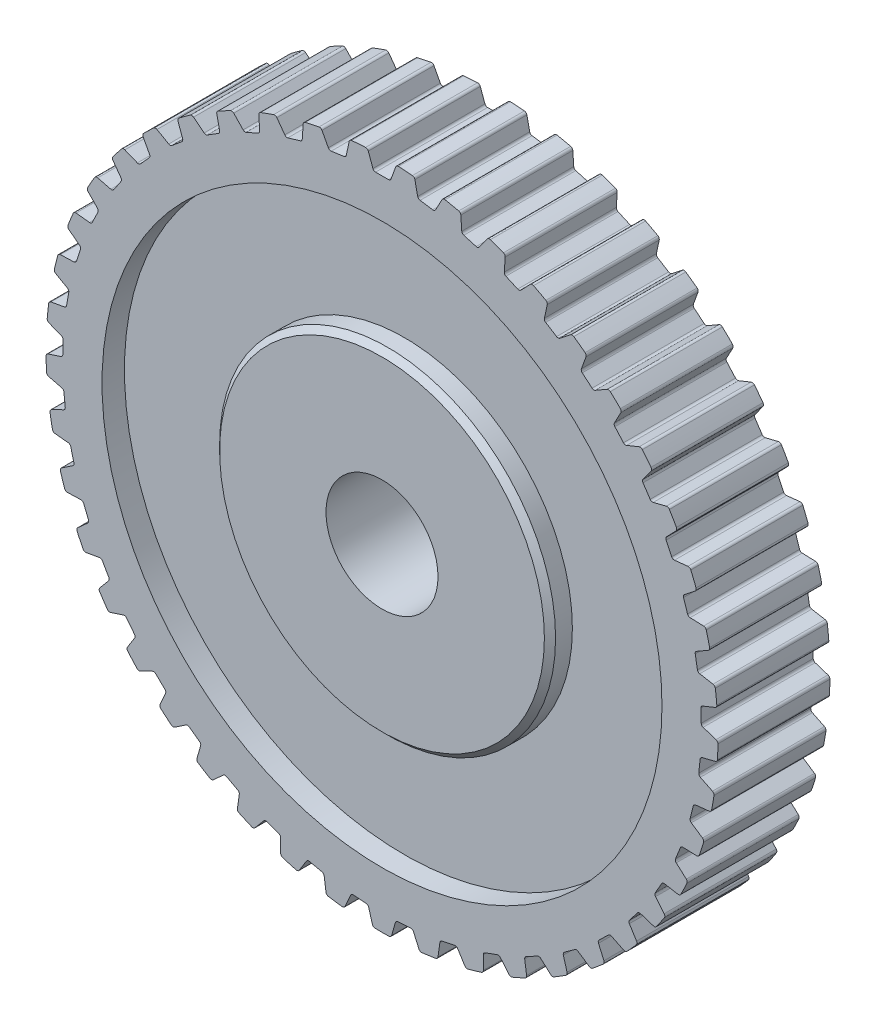
from build123d import *

# Parameters (mm, degrees)
SKETCH2_R               = 30
BOSS_EXTRUDE1_DEPTH     = 10
CUT_EXTRUDE1_START      = -11
CUT_EXTRUDE1_DEPTH      = 12
CIRPATTERN1_COUNT       = 45
SKETCH4_R               = 25
SKETCH4_R_2             = 15
CUT_EXTRUDE_THIN1_DEPTH = 2
CHAMFER1_SIZE           = 0.5
CHAMFER2_SIZE           = 0.5
FILLET1_R               = 0.25
BOSS_EXTRUDE2_DEPTH     = 10


with BuildPart() as part:
    # Sketch2 → Boss-Extrude1 (new body)
    with BuildSketch(Plane.XY):
        Circle(SKETCH2_R)
        with BuildLine():
            Line((2, 4.582575695), (2, 7))
            Line((2, 7), (-2, 7))
            Line((-2, 7), (-2, 4.582575695))
            ThreePointArc((-2, 4.582575695), (0, -5), (2, 4.582575695))
        make_face(mode=Mode.SUBTRACT)
    extrude(amount=BOSS_EXTRUDE1_DEPTH)

    # Sketch3 → Cut-Extrude1 (cut)
    with BuildSketch(Plane.XY.offset(10).offset(CUT_EXTRUDE1_START)):
        Polygon((-50.976281067, 166.495573095), (-1.285919783, 29.972427501), (-0.75, 28.5), (0.75, 28.5), (1.285919783, 29.972427501), (50.976281067, 166.495573095), (50.976281067, 457.065367035), (-50.976281067, 457.065367035), align=None)
    cut_extrude1 = extrude(amount=CUT_EXTRUDE1_DEPTH, mode=Mode.SUBTRACT)

    # CirPattern1: Cut-Extrude1 ×45 about axis
    cirpattern1_axis = Axis((0, 0, 0), (0, 0, 1))
    for i in range(1, CIRPATTERN1_COUNT):
        add(cut_extrude1.rotate(cirpattern1_axis, i * 360 / CIRPATTERN1_COUNT), mode=Mode.SUBTRACT)

    # Sketch4 → Cut-Extrude-Thin1 (cut)
    with BuildSketch(Plane.XY.offset(10)):
        Circle(SKETCH4_R)
        Circle(SKETCH4_R_2, mode=Mode.SUBTRACT)
    cut_extrude_thin1 = extrude(amount=-CUT_EXTRUDE_THIN1_DEPTH, mode=Mode.SUBTRACT)

    # Chamfer1
    chamfer1_edges = [part.edges().sort_by_distance(p)[0] for p in [
        (-15, 0, 10),
    ]]
    chamfer(chamfer1_edges, length=CHAMFER1_SIZE)

    # Mirror1: Cut-Extrude-Thin1 across plane
    add(cut_extrude_thin1.mirror(Plane.XY.offset(5)), mode=Mode.SUBTRACT)

    # Chamfer2
    chamfer2_edges = [part.edges().sort_by_distance(p)[0] for p in [
        (-15, 0, 0),
    ]]
    chamfer(chamfer2_edges, length=CHAMFER2_SIZE)

    # Fillet1
    fillet1_edges = [part.edges().sort_by_distance(p)[0] for p in [
        (5.444760978, 29.501772453, 5),
        (2.897950379, 29.859703341, 5),
        (-2.897950379, 29.859703341, 5),
        (-5.444760978, 29.501772453, 5),
        (-7.025415233, 29.16579402, 5),
        (-9.497626095, 28.456898963, 5),
        (-11.01613837, 27.904205694, 5),
        (-13.365630723, 26.858144303, 5),
        (-14.792444905, 26.099493745, 5),
        (-16.973488552, 24.736626415, 5),
        (-18.280833326, 23.786784837, 5),
        (-20.250976734, 22.133638231, 5),
        (-21.413406121, 21.01109322, 5),
        (-23.134302688, 19.099843956, 5),
        (-24.129191322, 17.826444573, 5),
        (-25.567345756, 15.694292943, 5),
        (-26.375329261, 14.29482446, 5),
        (-27.502749521, 11.983270371, 5),
        (-28.108101418, 10.484971849, 5),
        (-28.90284355, 8.039007072, 5),
        (-29.293781353, 6.471041187, 5),
        (-29.740376607, 3.938273644, 5),
        (-29.909291155, 2.33115907, 5),
        (-29.999047061, -0.2391138, 5),
        (9.497626095, 28.456898963, 5),
        (7.025415233, 29.16579402, 5),
        (13.365630723, 26.858144303, 5),
        (11.01613837, 27.904205694, 5),
        (16.973488552, 24.736626415, 5),
        (14.792444905, 26.099493745, 5),
        (20.250976734, 22.133638231, 5),
        (18.280833326, 23.786784837, 5),
        (23.134302688, 19.099843956, 5),
        (21.413406121, 21.01109322, 5),
        (25.567345756, 15.694292943, 5),
        (24.129191322, 17.826444573, 5),
        (27.502749521, 11.983270371, 5),
        (26.375329261, 14.29482446, 5),
        (28.90284355, 8.039007072, 5),
        (28.108101418, 10.484971849, 5),
        (29.740376607, 3.938273644, 5),
        (29.293781353, 6.471041187, 5),
        (29.999047061, -0.2391138, 5),
        (29.909291155, 2.33115907, 5),
        (29.673820188, -4.411847167, 5),
        (29.942650626, -1.854096408, 5),
        (28.771026159, -8.498708946, 5),
        (29.393210462, -6.003264007, 5),
        (27.308236832, -12.420153023, 5),
        (28.27166489, -10.035584902, 5),
        (25.313923738, -16.099852949, 5),
        (26.59984352, -13.872574552, 5),
        (22.826903912, -19.466187551, 5),
        (24.410286453, -17.439550318, 5),
        (19.895584367, -22.453634955, 5),
        (21.745610926, -20.667085074, 5),
        (16.577019903, -25.004047895, 5),
        (18.657681818, -23.492358527, 5),
        (12.935802603, -27.067785484, 5),
        (15.206602156, -25.860379944, 5),
        (9.042804619, -28.604679418, 5),
        (11.45954328, -27.725058482, 5),
        (4.97379873, -29.584815805, 5),
        (7.48943743, -29.050100292, 5),
        (0.807983505, -29.989117404, 5),
        (3.373558199, -29.809714945, 5),
        (-3.373558199, -29.809714945, 5),
        (-0.807983505, -29.989117404, 5),
        (-7.48943743, -29.050100292, 5),
        (-4.97379873, -29.584815805, 5),
        (-11.45954328, -27.725058482, 5),
        (-9.042804619, -28.604679418, 5),
        (-15.206602156, -25.860379944, 5),
        (-12.935802603, -27.067785484, 5),
        (-18.657681818, -23.492358527, 5),
        (-16.577019903, -25.004047895, 5),
        (-21.745610926, -20.667085074, 5),
        (-19.895584367, -22.453634955, 5),
        (-24.410286453, -17.439550318, 5),
        (-22.826903912, -19.466187551, 5),
        (-26.59984352, -13.872574552, 5),
        (-25.313923738, -16.099852949, 5),
        (-28.27166489, -10.035584902, 5),
        (-27.308236832, -12.420153023, 5),
        (-29.393210462, -6.003264007, 5),
        (-28.771026159, -8.498708946, 5),
        (-29.942650626, -1.854096408, 5),
        (-29.673820188, -4.411847167, 5),
        (0.75, 28.5, 5),
        (-0.75, 28.5, 5),
        (-1.285919783, 29.972427501, 5),
        (1.285919783, 29.972427501, 5),
        (-28.422270365, -2.233169782, 5),
        (-28.265477671, -3.724952625, 5),
        (-27.834869621, -6.16705223, 5),
        (-27.471986777, -7.622495819, 5),
        (-26.7056948, -9.980900021, 5),
        (-26.14378491, -11.371675803, 5),
        (-25.056724008, -13.600480947, 5),
        (-24.306724008, -14.899519053, 5),
        (-22.920052584, -16.955343982, 5),
        (-21.996560371, -18.137360112, 5),
        (-20.337268408, -19.980190532, 5),
        (-19.258258708, -21.022178087, 5),
        (-17.358642436, -22.6161454, 5),
        (-16.145116945, -23.497823279, 5),
        (-14.042150234, -24.811902724, 5),
        (-12.717728845, -25.516110069, 5),
        (-10.45234355, -26.524724585, 5),
        (-9.042804619, -27.0377548, 5),
        (-6.659093889, -27.721272853, 5),
        (-5.191872488, -28.033140389, 5),
        (-2.736232539, -28.378258077, 5),
        (-1.239886464, -28.482892788, 5),
        (1.239886464, -28.482892788, 5),
        (2.736232539, -28.378258077, 5),
        (5.191872488, -28.033140389, 5),
        (6.659093889, -27.721272853, 5),
        (9.042804619, -27.0377548, 5),
        (10.45234355, -26.524724585, 5),
        (12.717728845, -25.516110069, 5),
        (14.042150234, -24.811902724, 5),
        (16.145116945, -23.497823279, 5),
        (17.358642436, -22.6161454, 5),
        (19.258258708, -21.022178087, 5),
        (20.337268408, -19.980190532, 5),
        (21.996560371, -18.137360112, 5),
        (22.920052584, -16.955343982, 5),
        (24.306724008, -14.899519053, 5),
        (25.056724008, -13.600480947, 5),
        (26.14378491, -11.371675803, 5),
        (26.7056948, -9.980900021, 5),
        (27.471986777, -7.622495819, 5),
        (27.834869621, -6.16705223, 5),
        (28.265477671, -3.724952625, 5),
        (28.422270365, -2.233169782, 5),
        (28.508813193, 0.245092536, 5),
        (28.456463948, 1.744178776, 5),
        (28.197257094, 4.210367249, 5),
        (27.936784828, 5.687578878, 5),
        (27.33687346, 8.093691952, 5),
        (26.873347969, 9.520276727, 5),
        (25.94440868, 11.819482149, 5),
        (25.286851959, 13.167673218, 5),
        (24.046965495, 15.31521957, 5),
        (23.20817614, 16.558775928, 5),
        (21.681475481, 18.512863662, 5),
        (20.677779571, 19.6275809, 5),
        (18.893980208, 21.350175922, 5),
        (17.744913544, 22.314357336, 5),
        (15.738735103, 23.771931292, 5),
        (14.466662959, 24.566810189, 5),
        (12.277153421, 25.730993061, 5),
        (10.906835234, 26.341098025, 5),
        (8.576610913, 27.189230317, 5),
        (7.134718369, 27.602686351, 5),
        (-28.456463948, 1.744178776, 5),
        (-28.508813193, 0.245092536, 5),
        (-27.936784828, 5.687578878, 5),
        (-28.197257094, 4.210367249, 5),
        (-26.873347969, 9.520276727, 5),
        (-27.33687346, 8.093691952, 5),
        (-25.286851959, 13.167673218, 5),
        (-25.94440868, 11.819482149, 5),
        (-23.20817614, 16.558775928, 5),
        (-24.046965495, 15.315219569, 5),
        (-20.677779571, 19.6275809, 5),
        (-21.681475481, 18.512863662, 5),
        (-17.744913544, 22.314357336, 5),
        (-18.893980208, 21.350175922, 5),
        (-14.466662959, 24.566810189, 5),
        (-15.738735103, 23.771931292, 5),
        (-10.906835234, 26.341098025, 5),
        (-12.277153421, 25.730993061, 5),
        (-7.134718369, 27.602686351, 5),
        (-8.576610913, 27.189230317, 5),
        (-3.223732326, 28.327019785, 5),
        (-4.709134429, 28.118260133, 5),
        (4.709134429, 28.118260133, 5),
        (3.223732326, 28.327019785, 5),
    ]]
    fillet(fillet1_edges, radius=FILLET1_R)

    # Sketch5 → Boss-Extrude2 (add)
    with BuildSketch(Plane.XY.offset(10)):
        with BuildLine():
            Line((-2, 7), (2, 7))
            Line((2, 7), (2, 4.582575695))
            ThreePointArc((2, 4.582575695), (0, 5), (-2, 4.582575695))
            Line((-2, 4.582575695), (-2, 7))
        make_face()
    extrude(amount=-BOSS_EXTRUDE2_DEPTH)


solid = part.part
